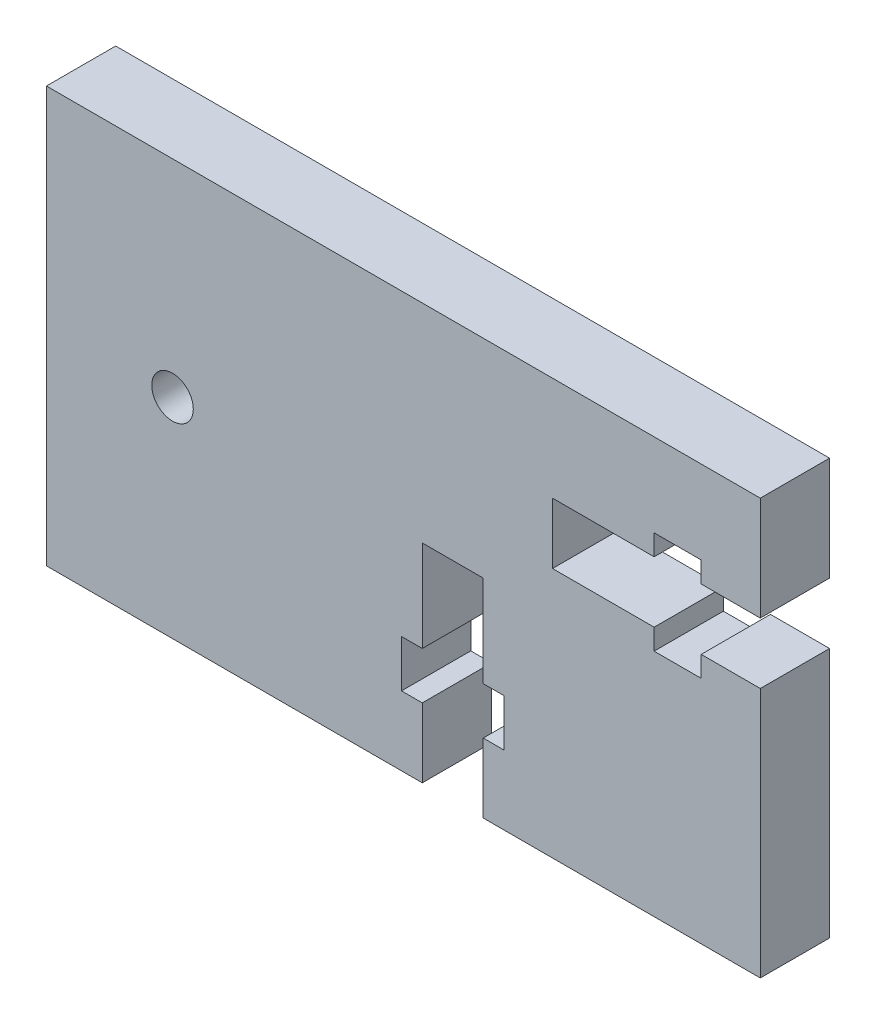
from build123d import *

# Parameters (mm, degrees)
SKETCH1_W           = 51.53
SKETCH1_H           = 30
BOSS_EXTRUDE1_DEPTH = 5
CUT_EXTRUDE1_DEPTH  = 5
SKETCH4_R           = 1.5
CUT_EXTRUDE3_DEPTH  = 5


with BuildPart() as part:
    # Sketch1 → Boss-Extrude1 (new body)
    with BuildSketch(Plane.XY):
        with Locations((2.765, -5)):
            Rectangle(SKETCH1_W, SKETCH1_H)
    extrude(amount=BOSS_EXTRUDE1_DEPTH)

    # Sketch2 → Cut-Extrude1 (cut)
    with BuildSketch(Plane.XY.offset(5)):
        Polygon((13.53, -1.9), (20.865904873, -1.9), (20.865904873, -3.4), (24.265904873, -3.4), (24.265904873, -1.9), (28.53, -1.9), (28.53, 2.5), (24.265904873, 2.5), (24.265904873, 4), (20.865904873, 4), (20.865904873, 2.5), (13.53, 2.5), align=None)
        Polygon((4.13, -5), (4.13, -11.6), (2.63, -11.6), (2.63, -15), (4.13, -15), (4.13, -20), (8.53, -20), (8.53, -15), (10.03, -15), (10.03, -11.6), (8.53, -11.6), (8.53, -5), align=None)
    extrude(amount=-CUT_EXTRUDE1_DEPTH, mode=Mode.SUBTRACT)

    # Sketch4 → Cut-Extrude3 (cut)
    with BuildSketch(Plane.XY.offset(5)):
        with Locations((-13.899616309, -4.903624059)):
            Circle(SKETCH4_R)
    extrude(amount=-CUT_EXTRUDE3_DEPTH, mode=Mode.SUBTRACT)


solid = part.part
